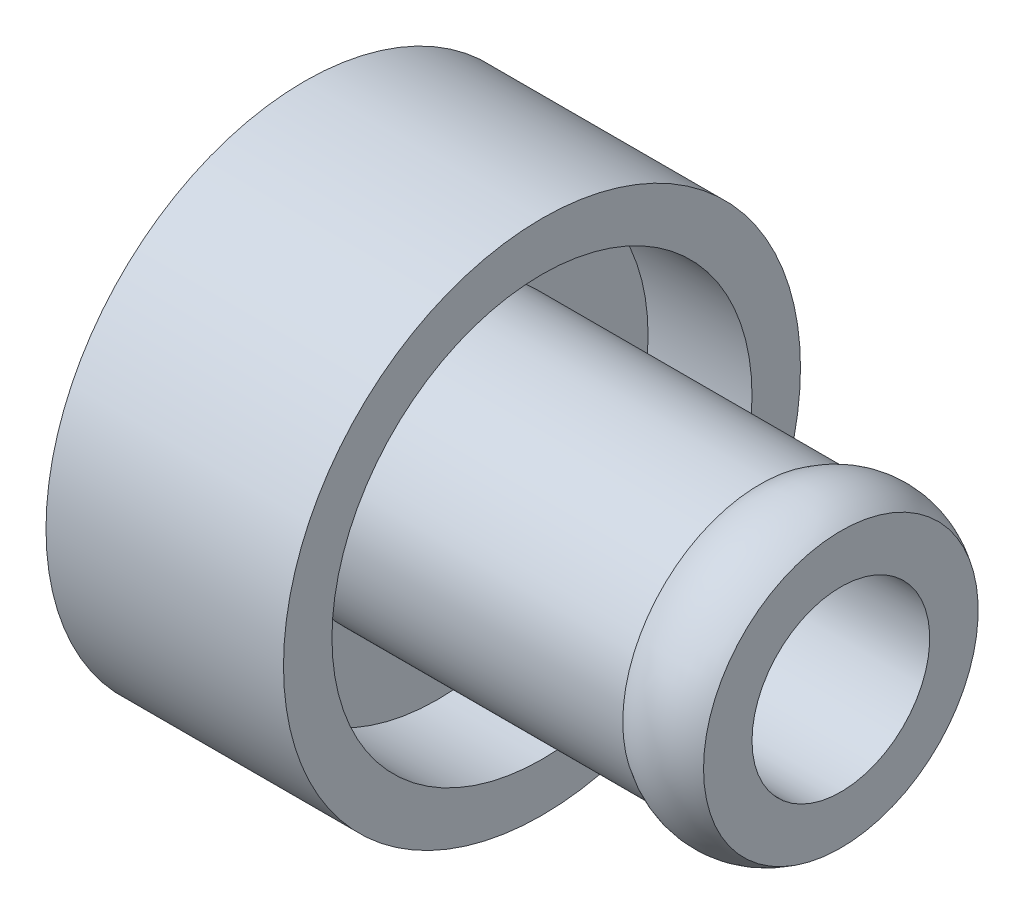
from build123d import *

# Parameters (mm, degrees)
SKETCH2_R          = 1.397
CUT_EXTRUDE1_DEPTH = 9.4328


with BuildPart() as part:
    # Sketch1 → Revolve1 (revolve)
    with BuildSketch(Plane.XY):
        Polygon((0, 0), (0, 2.159), (1.337955167, 2.159), (1.337955167, 3.302), (0, 3.302), (0, 4.064), (3.7338, 4.064), (3.7338, 3.302), (2.099955167, 3.302), (2.099955167, 2.159), (8.4328, 2.159), (8.4328, 0), align=None)
    revolve(axis=Axis((0, 0, 0), (1, 0, 0)))

    # Sketch2 → Cut-Extrude1 (cut, through all)
    with BuildSketch(Plane.ZY):
        Circle(SKETCH2_R)
    extrude(amount=-CUT_EXTRUDE1_DEPTH, mode=Mode.SUBTRACT)

    # Sketch3 → Revolve2 (revolve)
    with BuildSketch(Plane.XY):
        with BuildLine():
            Line((8.4328, 2.159), (7.1628, 2.159))
            ThreePointArc((7.1628, 2.159), (7.7978, 2.351594416), (8.4328, 2.159))
        make_face()
    revolve(axis=Axis((0, 0, 0), (1, 0, 0)))


solid = part.part
